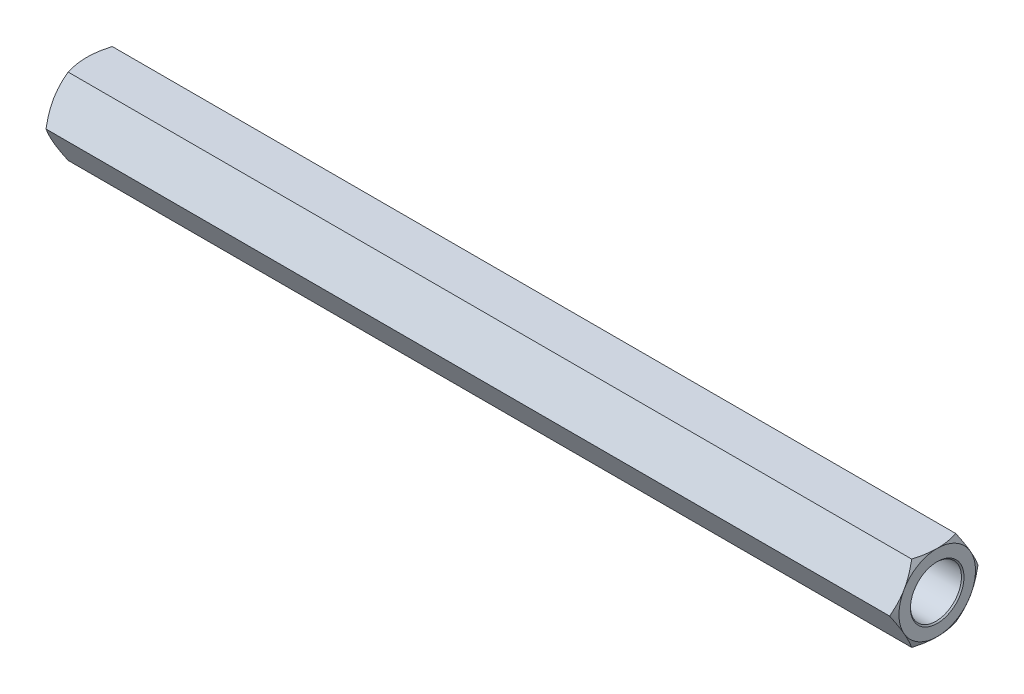
from build123d import *

# Parameters (mm, degrees)
BOSS_EXTRUDE1_DEPTH = 50
SKETCH4_OUTSIDE_W   = 193.96
SKETCH4_OUTSIDE_H   = 193.264
SKETCH4_OUTSIDE_R   = 2.25
CUT_EXTRUDE1_DEPTH  = 51
CUT_EXTRUDE1_TAPER  = 60
SKETCH5_OUTSIDE_W   = 193.96
SKETCH5_OUTSIDE_H   = 193.264
SKETCH5_OUTSIDE_R   = 2.25
CUT_EXTRUDE2_DEPTH  = 51
CUT_EXTRUDE2_TAPER  = 60


with BuildPart() as part:
    # Sketch2 → Boss-Extrude1 (new body)
    with BuildSketch(Plane(origin=(0, 0, 0), x_dir=(0, 0, -1), z_dir=(1, 0, 0))):
        Polygon((1.299038106, 2.25), (-1.299038106, 2.25), (-2.598076211, 0), (-1.299038106, -2.25), (1.299038106, -2.25), (2.598076211, 0), align=None)
    extrude(amount=BOSS_EXTRUDE1_DEPTH)

    # Sketch3 → Cut-Revolve1 (revolve, cut)
    with BuildSketch(Plane.XY):
        Polygon((0, 1.575), (0.075, 1.5), (6.3, 1.5), (6.3, 0), (0, 0), align=None)
        Polygon((50, 0), (43.7, 0), (43.7, 1.5), (49.925, 1.5), (50, 1.575), align=None)
    revolve(axis=Axis((0, 0, 0), (1, 0, 0)), mode=Mode.SUBTRACT)

    # Sketch4 outside → Cut-Extrude1 (cut, through all)
    with BuildSketch(Plane.ZY):
        Rectangle(SKETCH4_OUTSIDE_W, SKETCH4_OUTSIDE_H)
        Circle(SKETCH4_OUTSIDE_R, mode=Mode.SUBTRACT)
    extrude(amount=-CUT_EXTRUDE1_DEPTH, taper=CUT_EXTRUDE1_TAPER, mode=Mode.SUBTRACT)

    # Sketch5 outside → Cut-Extrude2 (cut, through all)
    with BuildSketch(Plane(origin=(50, 0, 0), x_dir=(0, 0, -1), z_dir=(1, 0, 0))):
        Rectangle(SKETCH5_OUTSIDE_W, SKETCH5_OUTSIDE_H)
        Circle(SKETCH5_OUTSIDE_R, mode=Mode.SUBTRACT)
    extrude(amount=-CUT_EXTRUDE2_DEPTH, taper=CUT_EXTRUDE2_TAPER, mode=Mode.SUBTRACT)


solid = part.part
